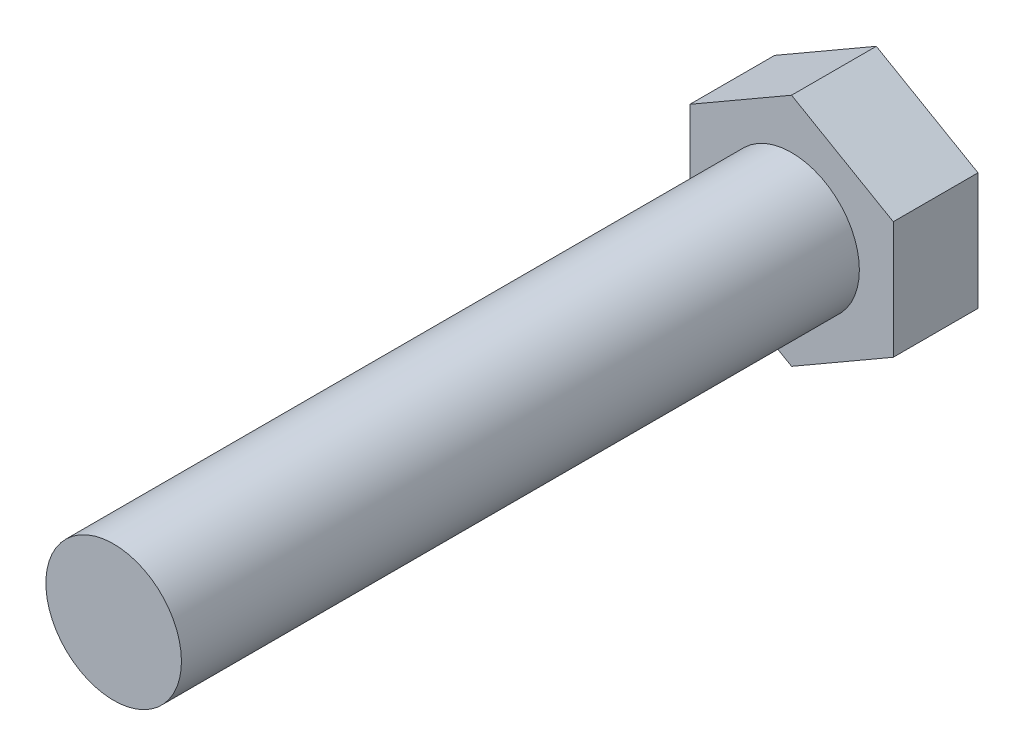
from build123d import *

# Parameters (mm, degrees)
P_IDAT_VYSUNUT_M1_DEPTH = 12.5
SKICA2_R                = 10
P_IDAT_VYSUNUT_M2_DEPTH = 100


with BuildPart() as part:
    # Skica1 → Přidat vysunutím1 (new body)
    with BuildSketch(Plane.XY):
        Polygon((15, 8.660254038), (0, 17.320508076), (-15, 8.660254038), (-15, -8.660254038), (0, -17.320508076), (15, -8.660254038), align=None)
    extrude(amount=P_IDAT_VYSUNUT_M1_DEPTH)

    # Skica2 → Přidat vysunutím2 (add)
    with BuildSketch(Plane.XY.offset(12.5)):
        Circle(SKICA2_R)
    extrude(amount=P_IDAT_VYSUNUT_M2_DEPTH)


solid = part.part
